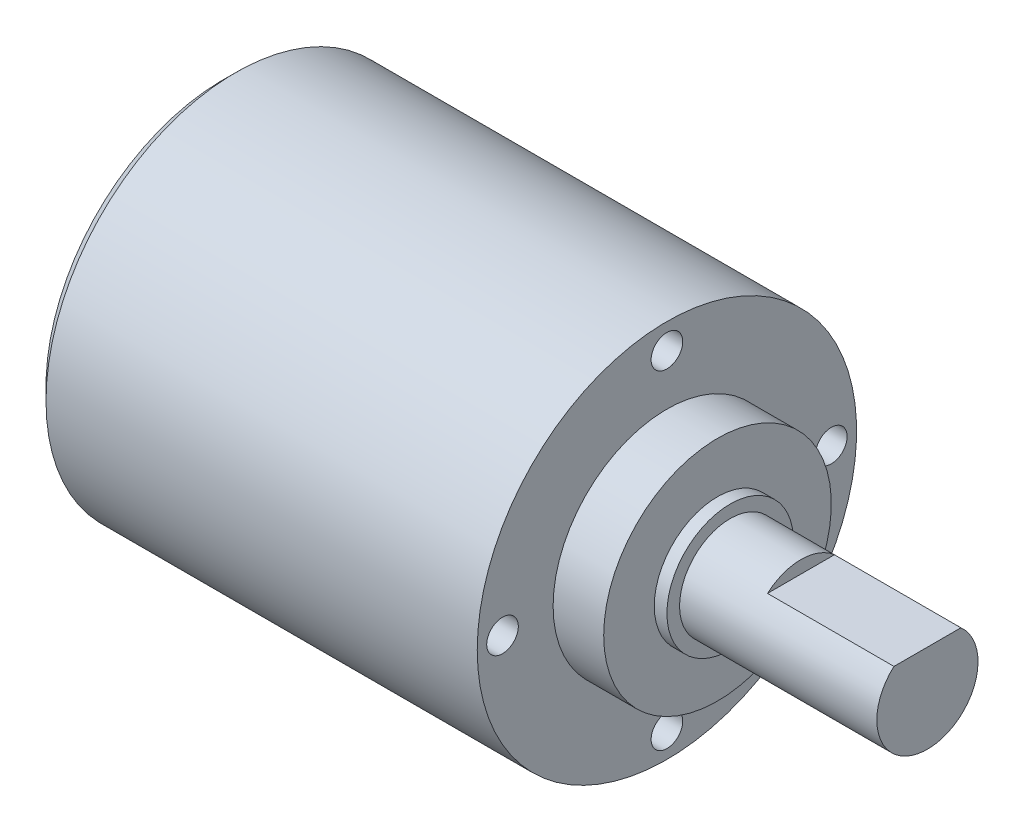
from build123d import *

# Parameters (mm, degrees)
EXTRUSION1_DEPTH             = 10
R_P_TITION_CIRCULAIRE1_COUNT = 4
CHANFREIN1_SIZE              = 1


with BuildPart() as part:
    # Esquisse1 → Révolution1 (revolve)
    with BuildSketch(Plane.XY):
        Polygon((27.85, 0), (27.85, 4), (12.25, 4), (12.25, 5), (11.25, 5), (11.25, 9), (7.25, 9), (7.25, 15), (-27.85, 15), (-27.85, 0), align=None)
    revolve(axis=Axis((-27.85, 0, 0), (1, 0, 0)))

    # Esquisse2 → Extrusion1 (cut)
    with BuildSketch(Plane(origin=(27.85, 0, 0), x_dir=(0, 0, -1), z_dir=(1, 0, 0))):
        with BuildLine():
            Line((2.645751311, 3), (-2.645751311, 3))
            ThreePointArc((-2.645751311, 3), (0, 4), (2.645751311, 3))
        make_face()
    extrude(amount=-EXTRUSION1_DEPTH, mode=Mode.SUBTRACT)

    # Esquisse3 → Trou taraudé M31 (revolve, cut)
    with BuildSketch(Plane(origin=(7.25, 13, 0), x_dir=(0, 0, -1), z_dir=(0, 1, 0))):
        Polygon((0, 0), (0, 6.251075774), (1.25, 5.5), (1.25, 0), align=None)
    trou_taraud_m31 = revolve(axis=Axis((13.6, 13, 0), (-1, 0, 0)), mode=Mode.SUBTRACT)

    # Répétition circulaire1: Trou taraudé M31 ×4 about axis
    r_p_tition_circulaire1_axis = Axis((0, 0, 0), (1, 0, 0))
    for i in range(1, R_P_TITION_CIRCULAIRE1_COUNT):
        add(trou_taraud_m31.rotate(r_p_tition_circulaire1_axis, i * 360 / R_P_TITION_CIRCULAIRE1_COUNT), mode=Mode.SUBTRACT)

    # Chanfrein1
    chanfrein1_edges = [part.edges().sort_by_distance(p)[0] for p in [
        (-27.85, -15, 0),
    ]]
    chamfer(chanfrein1_edges, length=CHANFREIN1_SIZE)


solid = part.part
